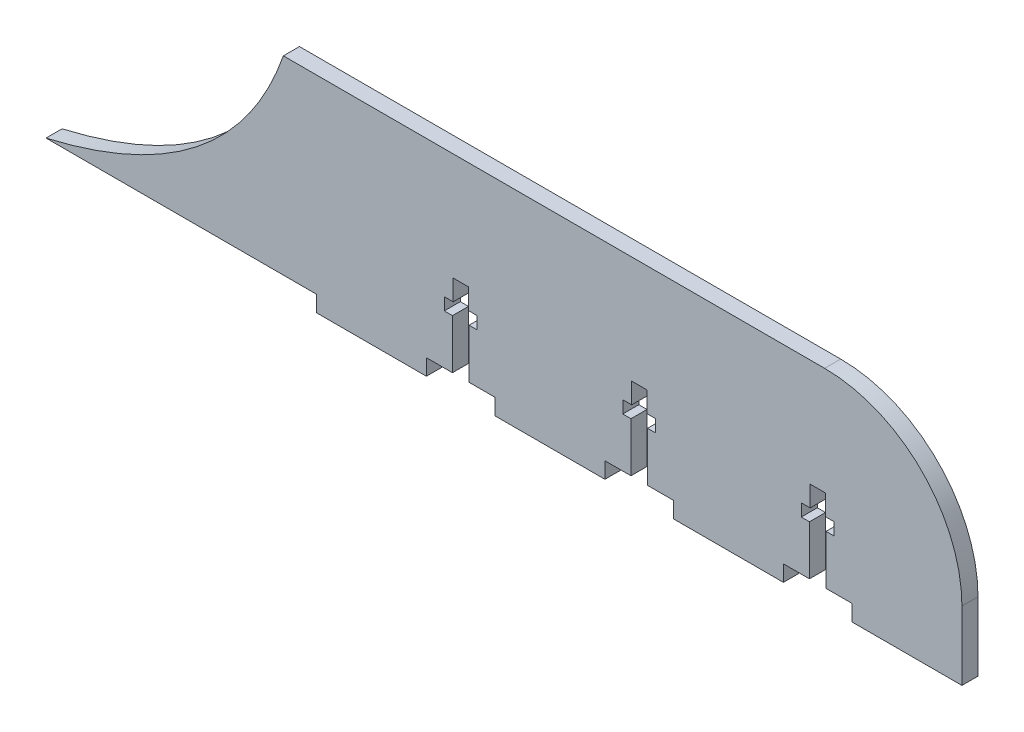
from build123d import *

# Parameters (mm, degrees)
BOSS_EXTRUDE2_DEPTH = 2.9718
SKETCH4_W           = 12.7
SKETCH4_H           = 2.972153091
CUT_EXTRUDE1_DEPTH  = 2.9718
CUT_EXTRUDE2_DEPTH  = 2.9718
FILLET1_R           = 25.4


with BuildPart() as part:
    # Sketch2 → Boss-Extrude2 (new body)
    with BuildSketch(Plane.XY):
        with BuildLine():
            Line((-190.5, 0), (0, 0))
            Line((0, 0), (0, 38.1))
            Line((0, 38.1), (-125.518660072, 38.1))
            add(Edge.make_bspline(
                [(-125.518660072, 38.1), (-137.686277491, 3.422332996), (-190.5, 0)],
                knots=[0, 0, 0, 1, 1, 1], degree=2))
        make_face()
    extrude(amount=BOSS_EXTRUDE2_DEPTH)

    # Sketch4 → Cut-Extrude1 (cut)
    with BuildSketch(Plane.XY.offset(2.9718)):
        with Locations((-26.67, 1.486076546)):
            Rectangle(SKETCH4_W, SKETCH4_H)
        with Locations((-59.69, 1.486076546)):
            Rectangle(SKETCH4_W, SKETCH4_H)
        with Locations((-92.71, 1.486076546)):
            Rectangle(SKETCH4_W, SKETCH4_H)
        with BuildLine():
            add(Edge.make_bspline(
                [(-169.427921187, 2.972153091), (-179.000448456, 0.745171762), (-190.5, 0)],
                knots=[0.782262052, 0.782262052, 0.782262052, 1, 1, 1], degree=2))
            Line((-190.5, 0), (-119.38, 0))
            Line((-119.38, 0), (-119.38, 2.972153091))
            Line((-119.38, 2.972153091), (-169.427921187, 2.972153091))
        make_face()
    extrude(amount=-CUT_EXTRUDE1_DEPTH, mode=Mode.SUBTRACT)

    # Sketch5 → Cut-Extrude2 (cut)
    with BuildSketch(Plane.XY.offset(2.9718)):
        Polygon((-91.313, 14.402153091), (-91.313, 18.212153091), (-94.107, 18.212153091), (-94.107, 14.402153091), (-95.758, 14.402153091), (-95.758, 12.116153091), (-94.244804958, 12.116153091), (-94.244804958, 2.972153091), (-91.175195042, 2.972153091), (-91.175195042, 12.116153091), (-89.662, 12.116153091), (-89.662, 14.402153091), align=None)
        Polygon((-58.293, 14.402153091), (-58.293, 18.212153091), (-61.087, 18.212153091), (-61.087, 14.402153091), (-62.738, 14.402153091), (-62.738, 12.116153091), (-61.224804958, 12.116153091), (-61.224804958, 2.972153091), (-58.155195042, 2.972153091), (-58.155195042, 12.116153091), (-56.642, 12.116153091), (-56.642, 14.402153091), align=None)
        Polygon((-26.67, 2.972153091), (-26.67, 18.212153091), (-28.067, 18.212153091), (-28.067, 14.402153091), (-29.718, 14.402153091), (-29.718, 12.116153091), (-28.204804958, 12.116153091), (-28.204804958, 2.972153091), align=None)
        Polygon((-25.273, 18.212153091), (-26.67, 18.212153091), (-26.67, 2.972153091), (-25.135195042, 2.972153091), (-25.135195042, 12.116153091), (-23.622, 12.116153091), (-23.622, 14.402153091), (-25.273, 14.402153091), align=None)
    extrude(amount=-CUT_EXTRUDE2_DEPTH, mode=Mode.SUBTRACT)

    # Fillet1
    fillet1_edges = [part.edges().sort_by_distance(p)[0] for p in [
        (0, 38.1, 1.4859),
    ]]
    fillet(fillet1_edges, radius=FILLET1_R)


solid = part.part
